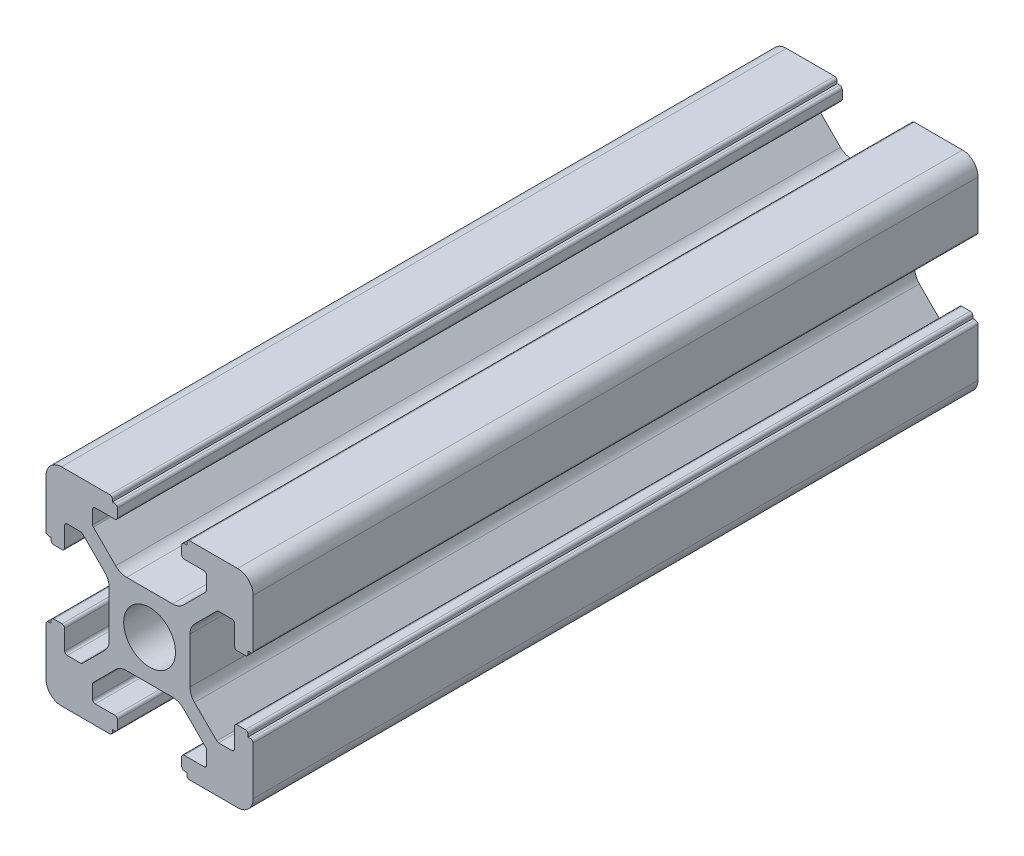
from build123d import *

# Parameters (mm, degrees)
SKETCH_1_R      = 2.5
EXTRUDE_1_DEPTH = 70


with BuildPart() as part:
    # 草图1 → 凸台-拉伸1 (new body)
    with BuildSketch(Plane.XY):
        with BuildLine():
            Line((-8.502261885, -10.002261885), (-3.85, -10.002261885))
            ThreePointArc((-3.85, -10.002261885), (-3.673223305, -9.929038581), (-3.6, -9.752261885))
            Line((-3.6, -9.752261885), (-3.6, -9.502261885))
            Line((-3.6, -9.502261885), (-3.35, -9.502261885))
            ThreePointArc((-3.35, -9.502261885), (-3.173223305, -9.429038581), (-3.1, -9.252261885))
            Line((-3.1, -9.252261885), (-3.1, -8.45))
            ThreePointArc((-3.1, -8.45), (-3.173223305, -8.273223305), (-3.35, -8.2))
            Line((-3.35, -8.2), (-5.25, -8.2))
            ThreePointArc((-5.25, -8.2), (-5.426776695, -8.126776695), (-5.5, -7.95))
            Line((-5.5, -7.95), (-5.5, -6.664213562))
            ThreePointArc((-5.5, -6.664213562), (-5.480969883, -6.568542704), (-5.426776695, -6.487436867))
            Line((-5.426776695, -6.487436867), (-3.278679656, -4.339339828))
            ThreePointArc((-3.278679656, -4.339339828), (-2.792044633, -4.014180701), (-2.218019485, -3.9))
            Line((-2.218019485, -3.9), (2.218019485, -3.9))
            ThreePointArc((2.218019485, -3.9), (2.792044633, -4.014180701), (3.278679656, -4.339339828))
            Line((3.278679656, -4.339339828), (5.426776695, -6.487436867))
            ThreePointArc((5.426776695, -6.487436867), (5.480969883, -6.568542704), (5.5, -6.664213562))
            Line((5.5, -6.664213562), (5.5, -7.95))
            ThreePointArc((5.5, -7.95), (5.426776695, -8.126776695), (5.25, -8.2))
            Line((5.25, -8.2), (3.35, -8.2))
            ThreePointArc((3.35, -8.2), (3.173223305, -8.273223305), (3.1, -8.45))
            Line((3.1, -8.45), (3.1, -9.252261885))
            ThreePointArc((3.1, -9.252261885), (3.173223305, -9.429038581), (3.35, -9.502261885))
            Line((3.35, -9.502261885), (3.6, -9.502261885))
            Line((3.6, -9.502261885), (3.6, -9.752261885))
            ThreePointArc((3.6, -9.752261885), (3.673223305, -9.929038581), (3.85, -10.002261885))
            Line((3.85, -10.002261885), (8.502261885, -10.002261885))
            ThreePointArc((8.502261885, -10.002261885), (9.562922057, -9.562922057), (10.002261885, -8.502261885))
            Line((10.002261885, -8.502261885), (10.002261885, -3.85))
            ThreePointArc((10.002261885, -3.85), (9.929038581, -3.673223305), (9.752261885, -3.6))
            Line((9.752261885, -3.6), (9.502261885, -3.6))
            Line((9.502261885, -3.6), (9.502261885, -3.35))
            ThreePointArc((9.502261885, -3.35), (9.429038581, -3.173223305), (9.252261885, -3.1))
            Line((9.252261885, -3.1), (8.45, -3.1))
            ThreePointArc((8.45, -3.1), (8.273223305, -3.173223305), (8.2, -3.35))
            Line((8.2, -3.35), (8.2, -5.25))
            ThreePointArc((8.2, -5.25), (8.126776695, -5.426776695), (7.95, -5.5))
            Line((7.95, -5.5), (6.664213562, -5.5))
            ThreePointArc((6.664213562, -5.5), (6.568542704, -5.480969883), (6.487436867, -5.426776695))
            Line((6.487436867, -5.426776695), (4.339339828, -3.278679656))
            ThreePointArc((4.339339828, -3.278679656), (4.014180701, -2.792044633), (3.9, -2.218019485))
            Line((3.9, -2.218019485), (3.9, 2.218019485))
            ThreePointArc((3.9, 2.218019485), (4.014180701, 2.792044633), (4.339339828, 3.278679656))
            Line((4.339339828, 3.278679656), (6.487436867, 5.426776695))
            ThreePointArc((6.487436867, 5.426776695), (6.568542704, 5.480969883), (6.664213562, 5.5))
            Line((6.664213562, 5.5), (7.95, 5.5))
            ThreePointArc((7.95, 5.5), (8.126776695, 5.426776695), (8.2, 5.25))
            Line((8.2, 5.25), (8.2, 3.35))
            ThreePointArc((8.2, 3.35), (8.273223305, 3.173223305), (8.45, 3.1))
            Line((8.45, 3.1), (9.252261885, 3.1))
            ThreePointArc((9.252261885, 3.1), (9.429038581, 3.173223305), (9.502261885, 3.35))
            Line((9.502261885, 3.35), (9.502261885, 3.6))
            Line((9.502261885, 3.6), (9.752261885, 3.6))
            ThreePointArc((9.752261885, 3.6), (9.929038581, 3.673223305), (10.002261885, 3.85))
            Line((10.002261885, 3.85), (10.002261885, 8.502261885))
            ThreePointArc((10.002261885, 8.502261885), (9.562922057, 9.562922057), (8.502261885, 10.002261885))
            Line((8.502261885, 10.002261885), (3.85, 10.002261885))
            ThreePointArc((3.85, 10.002261885), (3.673223305, 9.929038581), (3.6, 9.752261885))
            Line((3.6, 9.752261885), (3.6, 9.502261885))
            Line((3.6, 9.502261885), (3.35, 9.502261885))
            ThreePointArc((3.35, 9.502261885), (3.173223305, 9.429038581), (3.1, 9.252261885))
            Line((3.1, 9.252261885), (3.1, 8.45))
            ThreePointArc((3.1, 8.45), (3.173223305, 8.273223305), (3.35, 8.2))
            Line((3.35, 8.2), (5.25, 8.2))
            ThreePointArc((5.25, 8.2), (5.426776695, 8.126776695), (5.5, 7.95))
            Line((5.5, 7.95), (5.5, 6.664213562))
            ThreePointArc((5.5, 6.664213562), (5.480969883, 6.568542704), (5.426776695, 6.487436867))
            Line((5.426776695, 6.487436867), (3.278679656, 4.339339828))
            ThreePointArc((3.278679656, 4.339339828), (2.792044633, 4.014180701), (2.218019485, 3.9))
            Line((2.218019485, 3.9), (-2.218019485, 3.9))
            ThreePointArc((-2.218019485, 3.9), (-2.792044633, 4.014180701), (-3.278679656, 4.339339828))
            Line((-3.278679656, 4.339339828), (-5.426776695, 6.487436867))
            ThreePointArc((-5.426776695, 6.487436867), (-5.480969883, 6.568542704), (-5.5, 6.664213562))
            Line((-5.5, 6.664213562), (-5.5, 7.95))
            ThreePointArc((-5.5, 7.95), (-5.426776695, 8.126776695), (-5.25, 8.2))
            Line((-5.25, 8.2), (-3.35, 8.2))
            ThreePointArc((-3.35, 8.2), (-3.173223305, 8.273223305), (-3.1, 8.45))
            Line((-3.1, 8.45), (-3.1, 9.252261885))
            ThreePointArc((-3.1, 9.252261885), (-3.173223305, 9.429038581), (-3.35, 9.502261885))
            Line((-3.35, 9.502261885), (-3.6, 9.502261885))
            Line((-3.6, 9.502261885), (-3.6, 9.752261885))
            ThreePointArc((-3.6, 9.752261885), (-3.673223305, 9.929038581), (-3.85, 10.002261885))
            Line((-3.85, 10.002261885), (-8.502261885, 10.002261885))
            ThreePointArc((-8.502261885, 10.002261885), (-9.562922057, 9.562922057), (-10.002261885, 8.502261885))
            Line((-10.002261885, 8.502261885), (-10.002261885, 3.85))
            ThreePointArc((-10.002261885, 3.85), (-9.929038581, 3.673223305), (-9.752261885, 3.6))
            Line((-9.752261885, 3.6), (-9.502261885, 3.6))
            Line((-9.502261885, 3.6), (-9.502261885, 3.35))
            ThreePointArc((-9.502261885, 3.35), (-9.429038581, 3.173223305), (-9.252261885, 3.1))
            Line((-9.252261885, 3.1), (-8.45, 3.1))
            ThreePointArc((-8.45, 3.1), (-8.273223305, 3.173223305), (-8.2, 3.35))
            Line((-8.2, 3.35), (-8.2, 5.25))
            ThreePointArc((-8.2, 5.25), (-8.126776695, 5.426776695), (-7.95, 5.5))
            Line((-7.95, 5.5), (-6.664213562, 5.5))
            ThreePointArc((-6.664213562, 5.5), (-6.568542704, 5.480969883), (-6.487436867, 5.426776695))
            Line((-6.487436867, 5.426776695), (-4.339339828, 3.278679656))
            ThreePointArc((-4.339339828, 3.278679656), (-4.014180701, 2.792044633), (-3.9, 2.218019485))
            Line((-3.9, 2.218019485), (-3.9, -2.218019485))
            ThreePointArc((-3.9, -2.218019485), (-4.014180701, -2.792044633), (-4.339339828, -3.278679656))
            Line((-4.339339828, -3.278679656), (-6.487436867, -5.426776695))
            ThreePointArc((-6.487436867, -5.426776695), (-6.568542704, -5.480969883), (-6.664213562, -5.5))
            Line((-6.664213562, -5.5), (-7.95, -5.5))
            ThreePointArc((-7.95, -5.5), (-8.126776695, -5.426776695), (-8.2, -5.25))
            Line((-8.2, -5.25), (-8.2, -3.35))
            ThreePointArc((-8.2, -3.35), (-8.273223305, -3.173223305), (-8.45, -3.1))
            Line((-8.45, -3.1), (-9.252261885, -3.1))
            ThreePointArc((-9.252261885, -3.1), (-9.429038581, -3.173223305), (-9.502261885, -3.35))
            Line((-9.502261885, -3.35), (-9.502261885, -3.6))
            Line((-9.502261885, -3.6), (-9.752261885, -3.6))
            ThreePointArc((-9.752261885, -3.6), (-9.929038581, -3.673223305), (-10.002261885, -3.85))
            Line((-10.002261885, -3.85), (-10.002261885, -8.502261885))
            ThreePointArc((-10.002261885, -8.502261885), (-9.562922057, -9.562922057), (-8.502261885, -10.002261885))
        make_face()
        Circle(SKETCH_1_R, mode=Mode.SUBTRACT)
    extrude(amount=EXTRUDE_1_DEPTH)


solid = part.part
